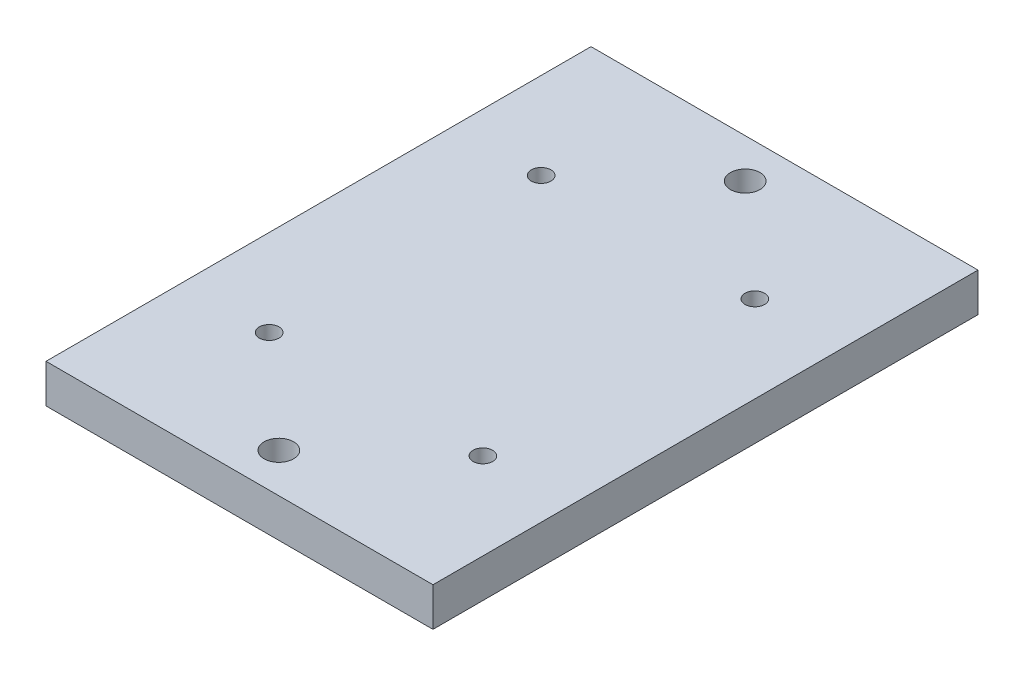
from build123d import *

# Parameters (mm, degrees)
SKETCH2_W           = 63.25
SKETCH2_H           = 89.08
BOSS_EXTRUDE1_DEPTH = 6.32
SKETCH3_R           = 2.415
CUT_EXTRUDE1_DEPTH  = 6.32
SKETCH4_R           = 2.415
CUT_EXTRUDE2_DEPTH  = 6.32
SKETCH5_W           = 50.72
SKETCH5_H           = 63.55
CUT_EXTRUDE3_DEPTH  = 1.37
FILLET1_R           = 6.35
SKETCH7_R           = 1.6
CUT_EXTRUDE4_DEPTH  = 5.95


with BuildPart() as part:
    # Sketch2 → Boss-Extrude1 (new body)
    with BuildSketch(Plane(origin=(0, 0, 0), x_dir=(1, 0, 0), z_dir=(0, 1, 0))):
        with Locations((31.625, 44.54)):
            Rectangle(SKETCH2_W, SKETCH2_H)
    extrude(amount=BOSS_EXTRUDE1_DEPTH)

    # Sketch3 → Cut-Extrude1 (cut)
    with BuildSketch(Plane(origin=(0, 0, 0), x_dir=(-1, 0, 0), z_dir=(0, -1, 0))):
        with Locations((-31.625, 82.65)):
            Circle(SKETCH3_R)
    extrude(amount=-CUT_EXTRUDE1_DEPTH, mode=Mode.SUBTRACT)

    # Sketch4 → Cut-Extrude2 (cut)
    with BuildSketch(Plane(origin=(0, 0, 0), x_dir=(-1, 0, 0), z_dir=(0, -1, 0))):
        with Locations((-31.625, 6.43)):
            Circle(SKETCH4_R)
    extrude(amount=-CUT_EXTRUDE2_DEPTH, mode=Mode.SUBTRACT)

    # Sketch5 → Cut-Extrude3 (cut)
    with BuildSketch(Plane(origin=(0, 0, 0), x_dir=(-1, 0, 0), z_dir=(0, -1, 0))):
        with Locations((-31.625, 44.54)):
            Rectangle(SKETCH5_W, SKETCH5_H)
    extrude(amount=-CUT_EXTRUDE3_DEPTH, mode=Mode.SUBTRACT)

    # Fillet1
    fillet1_edges = [part.edges().sort_by_distance(p)[0] for p in [
        (56.985, 0.685, -12.765),
        (56.985, 0.685, -76.315),
        (6.265, 0.685, -76.315),
        (6.265, 0.685, -12.765),
    ]]
    fillet(fillet1_edges, radius=FILLET1_R)

    # Sketch7 → Cut-Extrude4 (cut, through all)
    with BuildSketch(Plane(origin=(0, 1.37, 0), x_dir=(-1, 0, 0), z_dir=(0, -1, 0))):
        with Locations((-49.09, 22.315)):
            Circle(SKETCH7_R)
        with Locations((-49.09, 66.765)):
            Circle(SKETCH7_R)
        with Locations((-14.16, 66.765)):
            Circle(SKETCH7_R)
        with Locations((-14.16, 22.315)):
            Circle(SKETCH7_R)
    extrude(amount=-CUT_EXTRUDE4_DEPTH, mode=Mode.SUBTRACT)


solid = part.part
